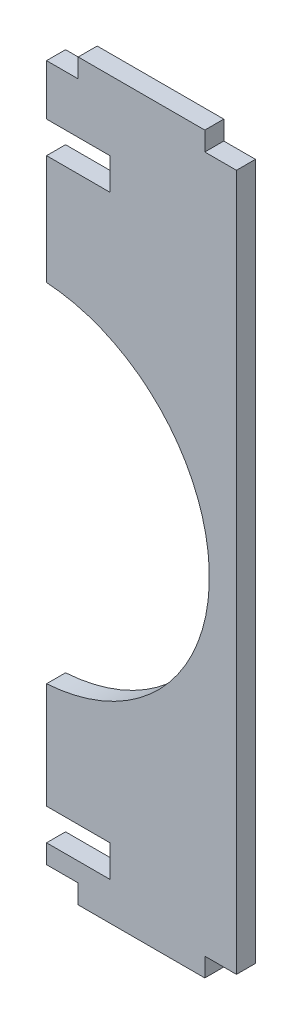
from build123d import *

# Parameters (mm, degrees)
BOSS_EXTRUDE1_DEPTH = 3
SKETCH2_W           = 10
SKETCH2_H           = 5
CUT_EXTRUDE1_DEPTH  = 3


with BuildPart() as part:
    # Sketch1 → Boss-Extrude1 (new body)
    with BuildSketch(Plane.XY):
        with BuildLine():
            Line((-5, 0), (-5, -3))
            Line((-5, -3), (0, -3))
            Line((0, -3), (0, -113.008152331))
            Line((0, -113.008152331), (-5, -113.008152331))
            Line((-5, -113.008152331), (-5, -116))
            Line((-5, -116), (-25, -116))
            Line((-25, -116), (-25, -113))
            Line((-25, -113), (-30, -113))
            Line((-30, -113), (-30, -88.243527021))
            ThreePointArc((-30, -88.243527021), (-4.280708477, -60.801240722), (-30, -33.358954423))
            Line((-30, -33.358954423), (-30, -3))
            Line((-30, -3), (-25, -3))
            Line((-25, -3), (-25, 0))
            Line((-25, 0), (-5, 0))
        make_face()
    extrude(amount=BOSS_EXTRUDE1_DEPTH)

    # Sketch2 → Cut-Extrude1 (cut)
    with BuildSketch(Plane.XY.offset(3)):
        with Locations((-25, -107.5)):
            Rectangle(SKETCH2_W, SKETCH2_H)
        with Locations((-25, -13.5)):
            Rectangle(SKETCH2_W, SKETCH2_H)
    extrude(amount=-CUT_EXTRUDE1_DEPTH, mode=Mode.SUBTRACT)


solid = part.part
